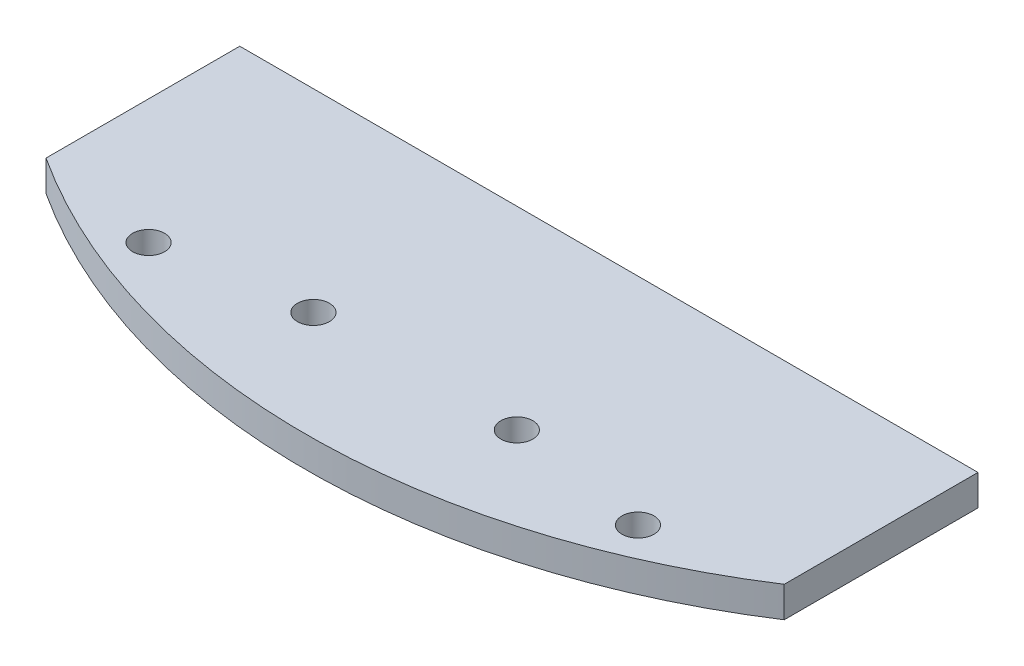
from build123d import *

# Parameters (mm, degrees)
SKETCH2_R           = 1.65
BOSS_EXTRUDE2_DEPTH = 3.175


with BuildPart() as part:
    # Sketch2 → Boss-Extrude2 (new body)
    with BuildSketch(Plane(origin=(0, 0, 0), x_dir=(1, 0, 0), z_dir=(0, 1, 0))):
        with BuildLine():
            Line((-38.1, -38.722993793), (-38.1, -58.722993793))
            ThreePointArc((-38.1, -58.722993793), (0, -70), (38.1, -58.722993793))
            Line((38.1, -58.722993793), (38.1, -38.722993793))
            Line((38.1, -38.722993793), (-38.1, -38.722993793))
        make_face()
        with Locations((-25.257106536, -60.976049146)):
            Circle(SKETCH2_R, mode=Mode.SUBTRACT)
        with Locations((25.257106536, -60.976049146)):
            Circle(SKETCH2_R, mode=Mode.SUBTRACT)
        with Locations((10.5, -58.722993793)):
            Circle(SKETCH2_R, mode=Mode.SUBTRACT)
        with Locations((-10.5, -58.722993793)):
            Circle(SKETCH2_R, mode=Mode.SUBTRACT)
    extrude(amount=BOSS_EXTRUDE2_DEPTH)


solid = part.part
